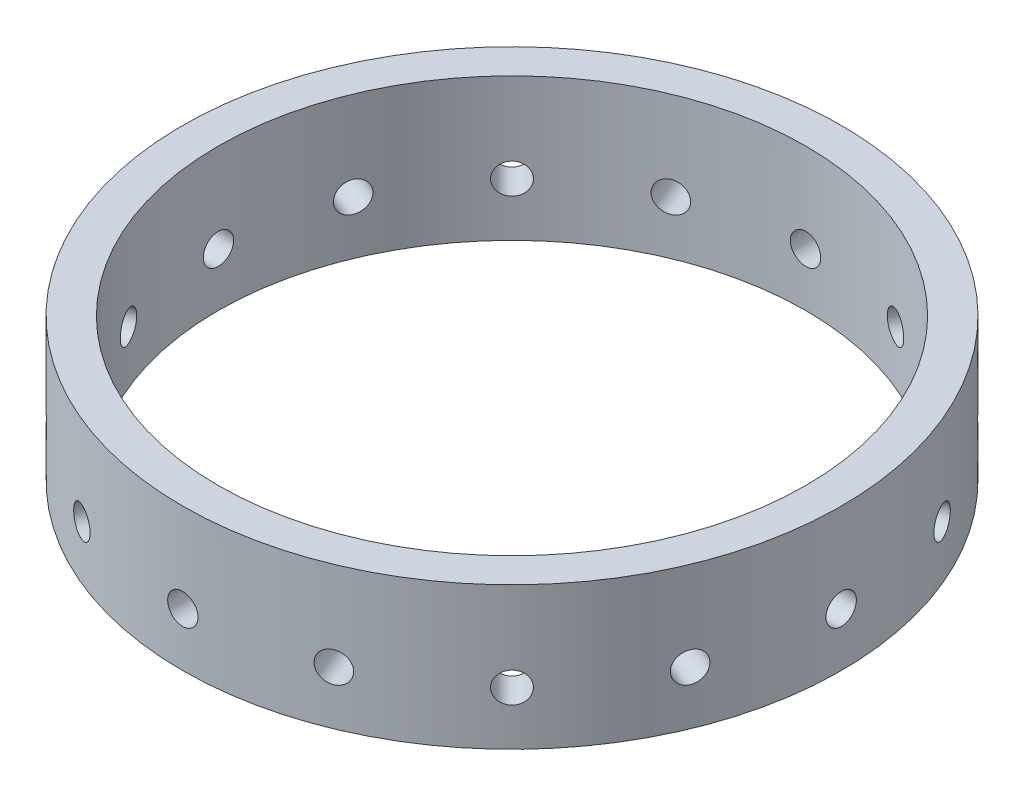
from build123d import *

# Parameters (mm, degrees)
SKETCH1_R                   = 58.7375
SKETCH1_R_2                 = 52.3875
BOSS_EXTRUDE1_DEPTH         = 25.4
TAP_DRILL_FOR_1_4_28_TAP1_D = 5.4102
CIRPATTERN1_COUNT           = 16


with BuildPart() as part:
    # Sketch1 → Boss-Extrude1 (new body)
    with BuildSketch(Plane(origin=(0, 0, 0), x_dir=(1, 0, 0), z_dir=(0, 1, 0))):
        Circle(SKETCH1_R)
        Circle(SKETCH1_R_2, mode=Mode.SUBTRACT)
    extrude(amount=BOSS_EXTRUDE1_DEPTH)

    # Tap Drill for 1/4-28 Tap1 (through all)
    with Locations(Plane(origin=(0, 0, -58.7375), x_dir=(-1, 0, 0), z_dir=(0, 0, -1))):
        with Locations((0, 9.525)):
            tap_drill_for_1_4_28_tap1 = Hole(TAP_DRILL_FOR_1_4_28_TAP1_D / 2)

    # CirPattern1: Tap Drill for 1/4-28 Tap1 ×16 about axis
    cirpattern1_axis = Axis((0, 0, 0), (0, 1, 0))
    for i in range(1, CIRPATTERN1_COUNT):
        add(tap_drill_for_1_4_28_tap1.rotate(cirpattern1_axis, i * 360 / CIRPATTERN1_COUNT), mode=Mode.SUBTRACT)


solid = part.part
